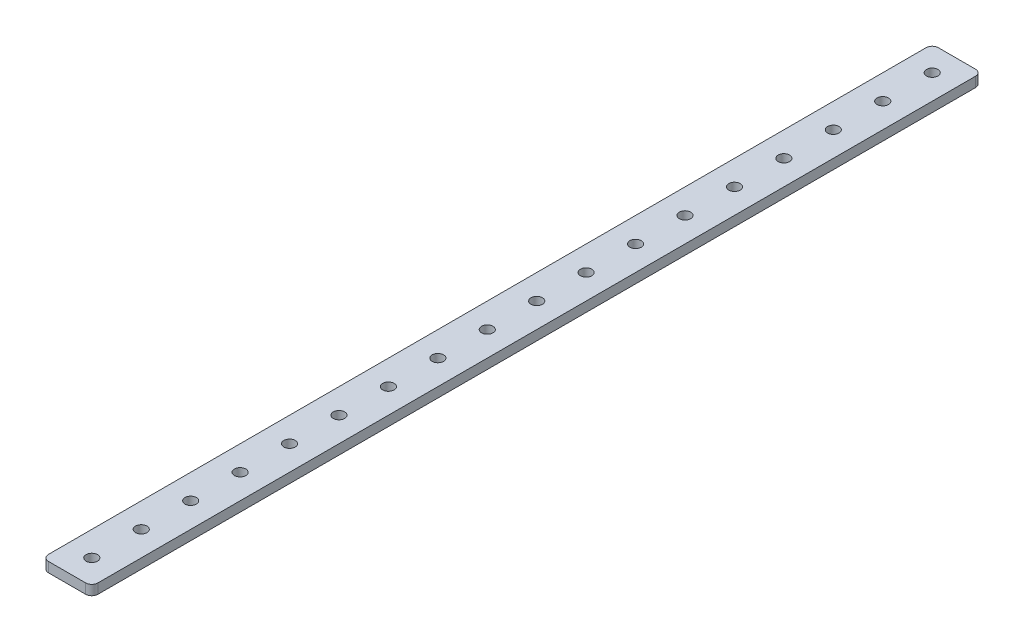
from build123d import *

# Parameters (mm, degrees)
SKETCH1_R           = 1.85
BOSS_EXTRUDE1_DEPTH = 3.2


with BuildPart() as part:
    # Sketch1 → Boss-Extrude1 (new body)
    with BuildSketch(Plane(origin=(0, 3.2, 0), x_dir=(1, 0, 0), z_dir=(0, 1, 0))):
        with BuildLine():
            Line((6, 288), (-6, 288))
            ThreePointArc((-6, 288), (-7.414213562, 287.414213562), (-8, 286))
            Line((-8, 286), (-8, 2))
            ThreePointArc((-8, 2), (-7.414213562, 0.585786438), (-6, 0))
            Line((-6, 0), (6, 0))
            ThreePointArc((6, 0), (7.414213562, 0.585786438), (8, 2))
            Line((8, 2), (8, 286))
            ThreePointArc((8, 286), (7.414213562, 287.414213562), (6, 288))
        make_face()
        with Locations((0, 8)):
            Circle(SKETCH1_R, mode=Mode.SUBTRACT)
        with Locations((0, 280)):
            Circle(SKETCH1_R, mode=Mode.SUBTRACT)
        with Locations((0, 264)):
            Circle(SKETCH1_R, mode=Mode.SUBTRACT)
        with Locations((0, 248)):
            Circle(SKETCH1_R, mode=Mode.SUBTRACT)
        with Locations((0, 232)):
            Circle(SKETCH1_R, mode=Mode.SUBTRACT)
        with Locations((0, 216)):
            Circle(SKETCH1_R, mode=Mode.SUBTRACT)
        with Locations((0, 200)):
            Circle(SKETCH1_R, mode=Mode.SUBTRACT)
        with Locations((0, 184)):
            Circle(SKETCH1_R, mode=Mode.SUBTRACT)
        with Locations((0, 168)):
            Circle(SKETCH1_R, mode=Mode.SUBTRACT)
        with Locations((0, 152)):
            Circle(SKETCH1_R, mode=Mode.SUBTRACT)
        with Locations((0, 136)):
            Circle(SKETCH1_R, mode=Mode.SUBTRACT)
        with Locations((0, 120)):
            Circle(SKETCH1_R, mode=Mode.SUBTRACT)
        with Locations((0, 104)):
            Circle(SKETCH1_R, mode=Mode.SUBTRACT)
        with Locations((0, 88)):
            Circle(SKETCH1_R, mode=Mode.SUBTRACT)
        with Locations((0, 72)):
            Circle(SKETCH1_R, mode=Mode.SUBTRACT)
        with Locations((0, 56)):
            Circle(SKETCH1_R, mode=Mode.SUBTRACT)
        with Locations((0, 40)):
            Circle(SKETCH1_R, mode=Mode.SUBTRACT)
        with Locations((0, 24)):
            Circle(SKETCH1_R, mode=Mode.SUBTRACT)
    extrude(amount=-BOSS_EXTRUDE1_DEPTH)


solid = part.part
